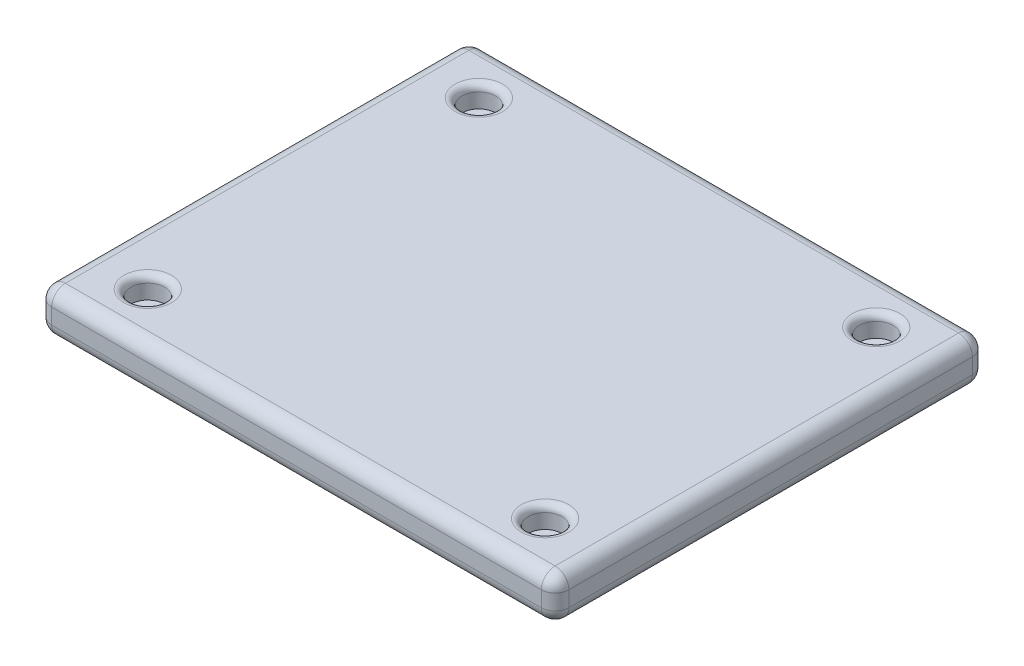
from build123d import *

# Parameters (mm, degrees)
SKETCH1_W           = 600
SKETCH1_H           = 500
BOSS_EXTRUDE1_DEPTH = 50
SKETCH2_R           = 19.6
CUT_EXTRUDE1_DEPTH  = 25
SCALE1_SCALE        = 0.125
FILLET4_R           = 1
FILLET7_R           = 2


with BuildPart() as part:
    # Sketch1 → Boss-Extrude1 (new body)
    with BuildSketch(Plane(origin=(0, 0, 0), x_dir=(1, 0, 0), z_dir=(0, 1, 0))):
        Rectangle(SKETCH1_W, SKETCH1_H)
    extrude(amount=BOSS_EXTRUDE1_DEPTH)

    # Sketch2 → Cut-Extrude1 (cut)
    with BuildSketch(Plane(origin=(0, 50, 0), x_dir=(1, 0, 0), z_dir=(0, 1, 0))):
        with Locations((-230.466383879, -192.055319899)):
            Circle(SKETCH2_R)
        with Locations((230.466383879, 192.055319899)):
            Circle(SKETCH2_R)
        with Locations((230.466383879, -192.055319899)):
            Circle(SKETCH2_R)
        with Locations((-230.466383879, 192.055319899)):
            Circle(SKETCH2_R)
    extrude(amount=-CUT_EXTRUDE1_DEPTH, mode=Mode.SUBTRACT)


with BuildPart() as part_1:
    # Scale1: scaled about (0, 24.898611392, 0)
    add(part.part.scale(SCALE1_SCALE).moved(Location((0, 21.786284968, 0))))

    # Fillet4
    fillet4_edges = [part_1.edges().sort_by_distance(p)[0] for p in [
        (-31.258297985, 28.036284968, -24.006914987),
        (26.358297985, 28.036284968, 24.006914987),
        (26.358297985, 28.036284968, -24.006914987),
        (-31.258297985, 28.036284968, 24.006914987),
    ]]
    fillet(fillet4_edges, radius=FILLET4_R)

    # Fillet7
    fillet7_edges = [part_1.edges().sort_by_distance(p)[0] for p in [
        (37.5, 28.036284968, 0),
        (0, 28.036284968, -31.25),
        (-37.5, 28.036284968, 0),
        (0, 21.786284968, -31.25),
        (37.5, 21.786284968, 0),
        (0, 21.786284968, 31.25),
        (-37.5, 21.786284968, 0),
        (-37.5, 24.911284968, -31.25),
        (37.5, 24.911284968, -31.25),
        (37.5, 24.911284968, 31.25),
        (-37.5, 24.911284968, 31.25),
        (0, 28.036284968, 31.25),
    ]]
    fillet(fillet7_edges, radius=FILLET7_R)


solid = part_1.part
